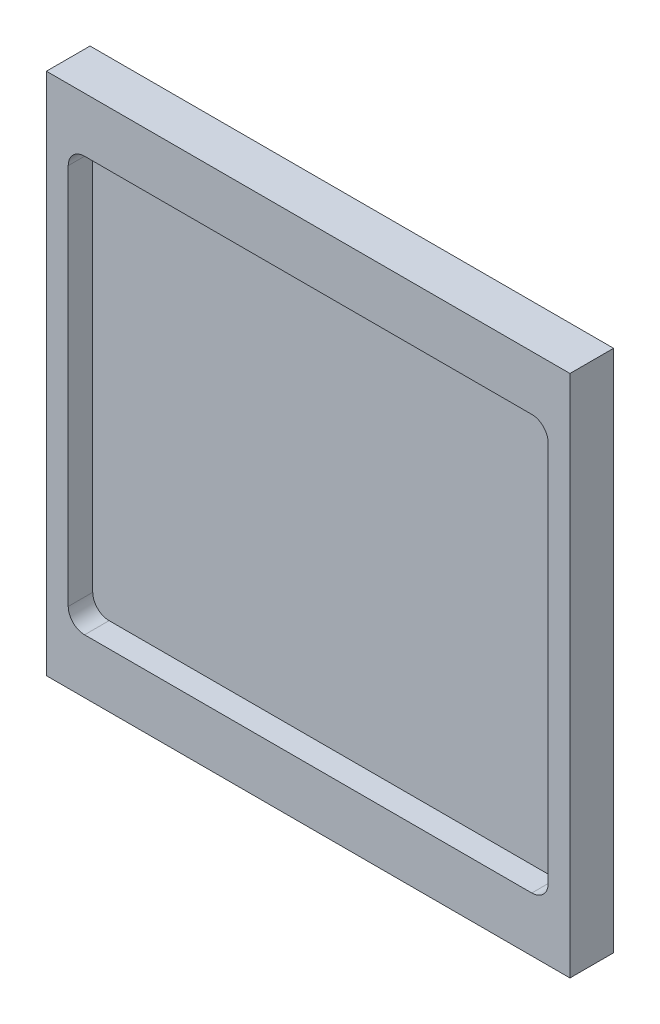
from build123d import *

# Parameters (mm, degrees)
SKETCH1_W           = 152.4
SKETCH1_H           = 152.4
BOSS_EXTRUDE1_DEPTH = 12.7
CUT_EXTRUDE1_DEPTH  = 7.1374


with BuildPart() as part:
    # Sketch1 → Boss-Extrude1 (new body)
    with BuildSketch(Plane.XY):
        Rectangle(SKETCH1_W, SKETCH1_H)
    extrude(amount=BOSS_EXTRUDE1_DEPTH)

    # Sketch2 → Cut-Extrude1 (cut)
    with BuildSketch(Plane.XY.offset(12.7)):
        with BuildLine():
            Line((-65.0875, 60.325), (65.0875, 60.325))
            ThreePointArc((65.0875, 60.325), (68.455096045, 58.930096045), (69.85, 55.5625))
            Line((69.85, 55.5625), (69.85, -55.5625))
            ThreePointArc((69.85, -55.5625), (68.455096045, -58.930096045), (65.0875, -60.325))
            Line((65.0875, -60.325), (-65.0875, -60.325))
            ThreePointArc((-65.0875, -60.325), (-68.455096045, -58.930096045), (-69.85, -55.5625))
            Line((-69.85, -55.5625), (-69.85, 55.5625))
            ThreePointArc((-69.85, 55.5625), (-68.455096045, 58.930096045), (-65.0875, 60.325))
        make_face()
    extrude(amount=-CUT_EXTRUDE1_DEPTH, mode=Mode.SUBTRACT)


solid = part.part
